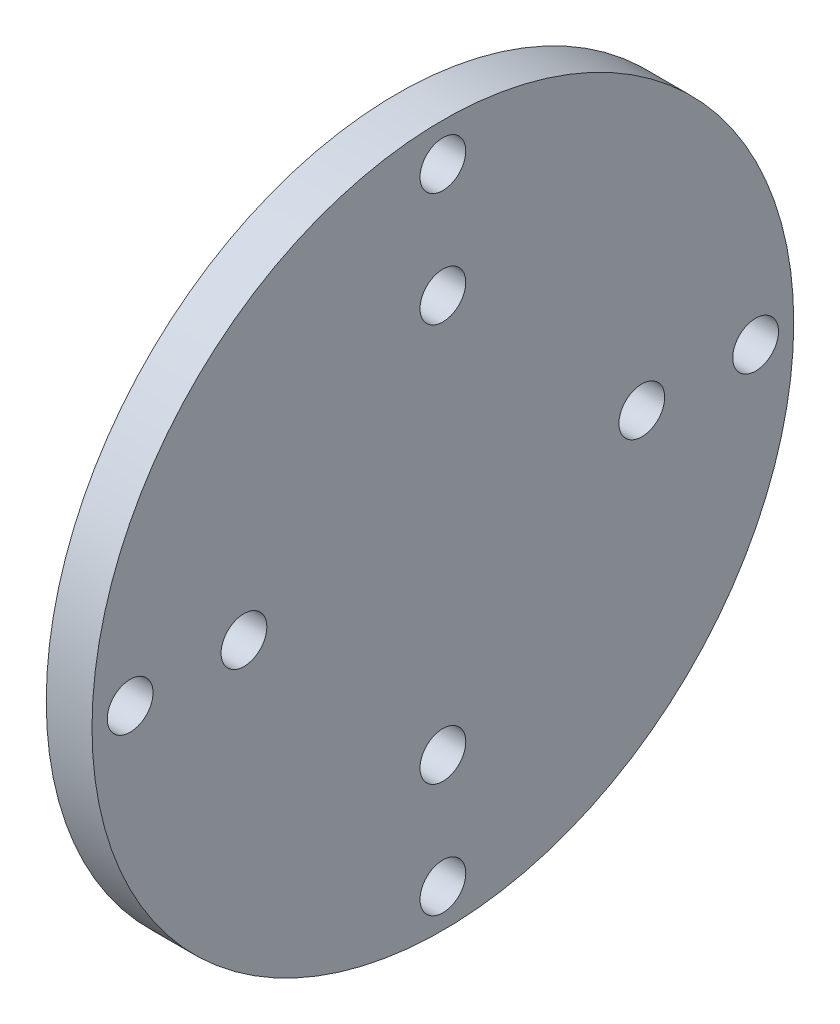
from build123d import *

# Parameters (mm, degrees)
SKETCH1_R           = 23
SKETCH1_R_2         = 1.5
BOSS_EXTRUDE1_DEPTH = 3


with BuildPart() as part:
    # Sketch1 → Boss-Extrude1 (new body)
    with BuildSketch(Plane(origin=(0, 0, 0), x_dir=(0, 0, -1), z_dir=(1, 0, 0))):
        with Locations((0, 16.5)):
            Circle(SKETCH1_R)
        with Locations((0, -4)):
            Circle(SKETCH1_R_2, mode=Mode.SUBTRACT)
        with Locations((0, 3.46)):
            Circle(SKETCH1_R_2, mode=Mode.SUBTRACT)
        with Locations((-13.04, 16.5)):
            Circle(SKETCH1_R_2, mode=Mode.SUBTRACT)
        with Locations((-20.5, 16.5)):
            Circle(SKETCH1_R_2, mode=Mode.SUBTRACT)
        with Locations((0, 29.54)):
            Circle(SKETCH1_R_2, mode=Mode.SUBTRACT)
        with Locations((0, 37)):
            Circle(SKETCH1_R_2, mode=Mode.SUBTRACT)
        with Locations((13.04, 16.5)):
            Circle(SKETCH1_R_2, mode=Mode.SUBTRACT)
        with Locations((20.5, 16.5)):
            Circle(SKETCH1_R_2, mode=Mode.SUBTRACT)
    extrude(amount=BOSS_EXTRUDE1_DEPTH)


solid = part.part
